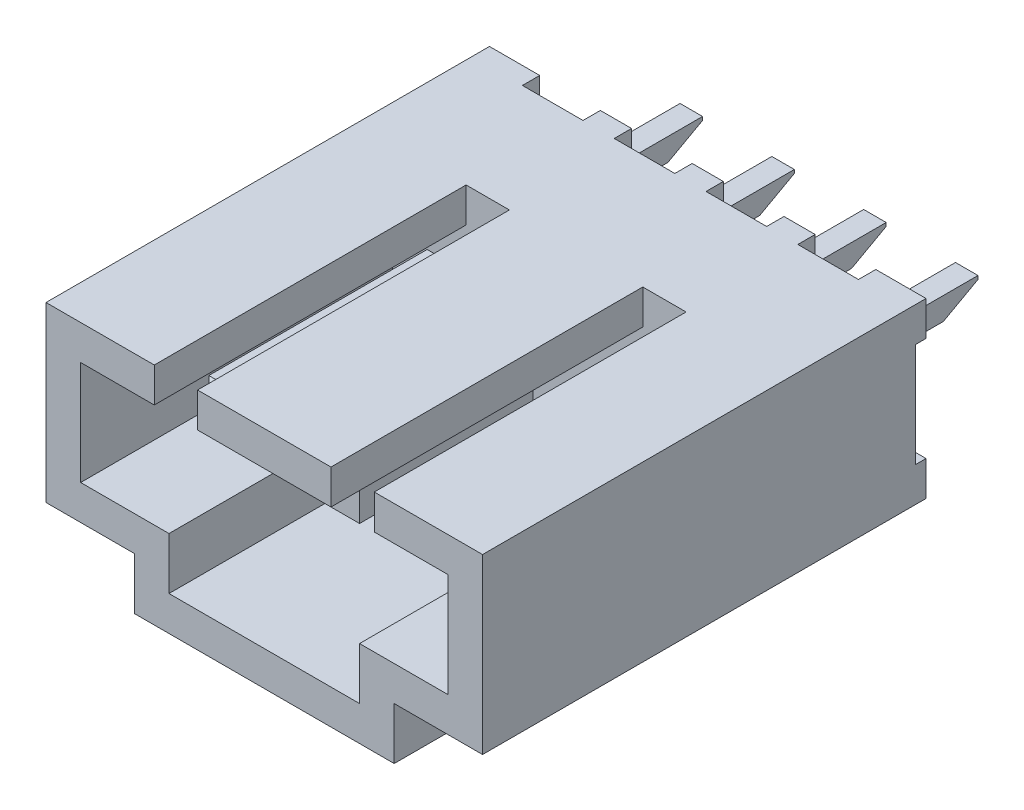
from build123d import *

# Parameters (mm, degrees)
BOSS_EXTRUDE1_DEPTH   = 12.8
CUT_EXTRUDE2_DEPTH    = 9
SKETCH5_W             = 1.5
SKETCH5_H             = 1
CUT_EXTRUDE3_DEPTH    = 4
SKETCH6_W             = 0.65
SKETCH6_H             = 0.65
BOSS_EXTRUDE3_DEPTH   = 13.8
BOSS_EXTRUDE3_2_DEPTH = 13.8
BOSS_EXTRUDE3_3_DEPTH = 13.8
BOSS_EXTRUDE3_4_DEPTH = 13.8
SKETCH7_W             = 1.75
SKETCH7_H             = 0.5
CUT_EXTRUDE5_DEPTH    = 7.5
SKETCH8_W             = 0.3
SKETCH8_H             = 3
CUT_EXTRUDE6_DEPTH    = 13.6
CUT_EXTRUDE7_DEPTH    = 11.6
CHAMFER1_SIZE         = 0.2
CHAMFER2_SIZE         = 0.2
CHAMFER3_SIZE         = 0.2
CHAMFER4_SIZE         = 0.2


with BuildPart() as part:
    # Sketch1 → Boss-Extrude1 (new body)
    with BuildSketch(Plane.XY):
        Polygon((0, 0), (6.3, 0), (6.3, -5), (3.75, -5), (3.75, -6.5), (0, -6.5), (-3.75, -6.5), (-3.75, -5), (-6.3, -5), (-6.3, 0), align=None)
    extrude(amount=BOSS_EXTRUDE1_DEPTH)

    # Sketch4 → Cut-Extrude2 (cut)
    with BuildSketch(Plane.XY.offset(12.8)):
        Polygon((-2.75, -4), (-1.25, -4), (-1.25, -5), (-2.75, -5), (-2.75, -5.5), (2.75, -5.5), (2.75, -5), (1.25, -5), (1.25, -4), (2.75, -4), (5.3, -4), (5.3, -1), (3.175, -1), (3.175, 0), (1.925, 0), (1.925, -1), (-1.925, -1), (-1.925, 0), (-3.175, 0), (-3.175, -1), (-5.3, -1), (-5.3, -4), align=None)
    extrude(amount=-CUT_EXTRUDE2_DEPTH, mode=Mode.SUBTRACT)

    # Sketch5 → Cut-Extrude3 (cut)
    with BuildSketch(Plane.XY.offset(12.8)):
        with Locations((-2, -4.5)):
            Rectangle(SKETCH5_W, SKETCH5_H)
        with Locations((2, -4.5)):
            Rectangle(SKETCH5_W, SKETCH5_H)
    extrude(amount=-CUT_EXTRUDE3_DEPTH, mode=Mode.SUBTRACT)

    # Sketch7 → Cut-Extrude5 (cut, through all)
    with BuildSketch(Plane(origin=(0, 0, 0), x_dir=(1, 0, 0), z_dir=(0, 1, 0))):
        with Locations((-3.975, -0.25)):
            Rectangle(SKETCH7_W, SKETCH7_H)
        with Locations((-1.325, -0.25)):
            Rectangle(SKETCH7_W, SKETCH7_H)
        with Locations((1.325, -0.25)):
            Rectangle(SKETCH7_W, SKETCH7_H)
        with Locations((3.975, -0.25)):
            Rectangle(SKETCH7_W, SKETCH7_H)
    extrude(amount=-CUT_EXTRUDE5_DEPTH, mode=Mode.SUBTRACT)

    # Sketch8 → Cut-Extrude6 (cut, through all)
    with BuildSketch(Plane.ZY.offset(6.3)):
        with Locations((0.15, -2.5)):
            Rectangle(SKETCH8_W, SKETCH8_H)
    extrude(amount=-CUT_EXTRUDE6_DEPTH, mode=Mode.SUBTRACT)


with BuildPart() as body_2:
    # Sketch6 → Boss-Extrude3 (new body)
    with BuildSketch(Plane.XY.offset(10.3)):
        with Locations((1.325, -2.5)):
            Rectangle(SKETCH6_W, SKETCH6_H)
    extrude(amount=-BOSS_EXTRUDE3_DEPTH)


with BuildPart() as body_3:
    # Sketch6 → Boss-Extrude3 2 (new body)
    with BuildSketch(Plane.XY.offset(10.3)):
        with Locations((3.975, -2.5)):
            Rectangle(SKETCH6_W, SKETCH6_H)
    extrude(amount=-BOSS_EXTRUDE3_2_DEPTH)


with BuildPart() as body_4:
    # Sketch6 → Boss-Extrude3 3 (new body)
    with BuildSketch(Plane.XY.offset(10.3)):
        with Locations((-3.975, -2.5)):
            Rectangle(SKETCH6_W, SKETCH6_H)
    extrude(amount=-BOSS_EXTRUDE3_3_DEPTH)


with BuildPart() as body_5:
    # Sketch6 → Boss-Extrude3 4 (new body)
    with BuildSketch(Plane.XY.offset(10.3)):
        with Locations((-1.325, -2.5)):
            Rectangle(SKETCH6_W, SKETCH6_H)
    extrude(amount=-BOSS_EXTRUDE3_4_DEPTH)


with BuildPart() as cut_extrude7_tool:
    # Sketch9 → Cut-Extrude7 (new body, through all)
    with BuildSketch(Plane.ZY.offset(4.3)):
        Polygon((-3.5, -2.275), (-2.5, -2.825), (-3.5, -2.825), align=None)
    extrude(amount=-CUT_EXTRUDE7_DEPTH)


with BuildPart() as body_2_1:
    add(body_2.part)

    # Cut-Extrude7: cut by cut_extrude7_tool
    add(cut_extrude7_tool.part, mode=Mode.SUBTRACT)

    # Chamfer3
    chamfer3_edges = [body_2_1.edges().sort_by_distance(p)[0] for p in [
        (1.325, -2.175, 10.3),
        (1.65, -2.5, 10.3),
        (1.325, -2.825, 10.3),
        (1, -2.5, 10.3),
    ]]
    chamfer(chamfer3_edges, length=CHAMFER3_SIZE)


with BuildPart() as body_3_1:
    add(body_3.part)

    # Cut-Extrude7: cut by cut_extrude7_tool
    add(cut_extrude7_tool.part, mode=Mode.SUBTRACT)

    # Chamfer4
    chamfer4_edges = [body_3_1.edges().sort_by_distance(p)[0] for p in [
        (3.975, -2.175, 10.3),
        (4.3, -2.5, 10.3),
        (3.975, -2.825, 10.3),
        (3.65, -2.5, 10.3),
    ]]
    chamfer(chamfer4_edges, length=CHAMFER4_SIZE)


with BuildPart() as body_4_1:
    add(body_4.part)

    # Cut-Extrude7: cut by cut_extrude7_tool
    add(cut_extrude7_tool.part, mode=Mode.SUBTRACT)

    # Chamfer2
    chamfer2_edges = [body_4_1.edges().sort_by_distance(p)[0] for p in [
        (-3.975, -2.825, 10.3),
        (-4.3, -2.5, 10.3),
        (-3.975, -2.175, 10.3),
        (-3.65, -2.5, 10.3),
    ]]
    chamfer(chamfer2_edges, length=CHAMFER2_SIZE)


with BuildPart() as body_5_1:
    add(body_5.part)

    # Cut-Extrude7: cut by cut_extrude7_tool
    add(cut_extrude7_tool.part, mode=Mode.SUBTRACT)

    # Chamfer1
    chamfer1_edges = [body_5_1.edges().sort_by_distance(p)[0] for p in [
        (-1.325, -2.825, 10.3),
        (-1.65, -2.5, 10.3),
        (-1.325, -2.175, 10.3),
        (-1, -2.5, 10.3),
    ]]
    chamfer(chamfer1_edges, length=CHAMFER1_SIZE)


solid = Compound([part.part, body_2_1.part, body_3_1.part, body_4_1.part, body_5_1.part])
